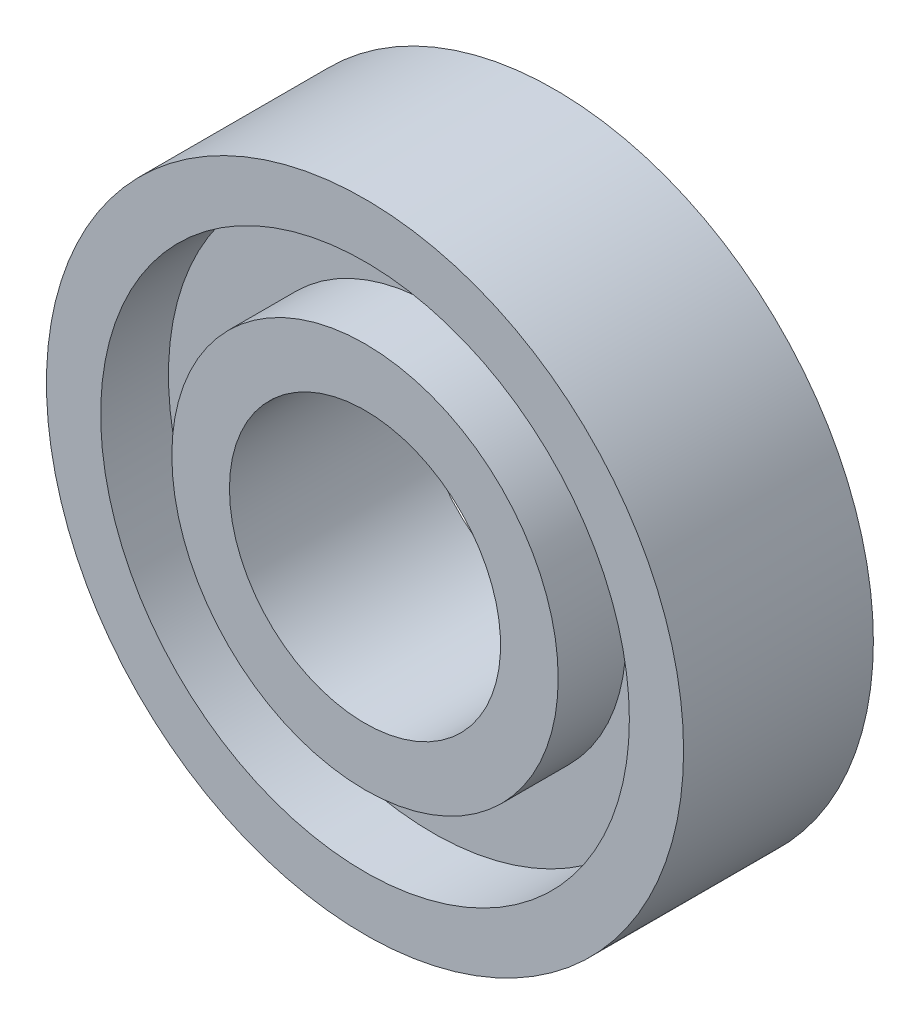
from build123d import *

# Parameters (mm, degrees)
SKETCH1_R      = 23.5
EXTRUDE1_DEPTH = 14
SKETCH2_R      = 19.5
SKETCH2_R_2    = 14.25
EXTRUDE2_DEPTH = 5
SKETCH3_R      = 19.5
SKETCH3_R_2    = 14.25
EXTRUDE3_DEPTH = 5
SKETCH4_R      = 10
EXTRUDE4_DEPTH = 15


with BuildPart() as part:
    # Sketch1 → Extrude1 (new body)
    with BuildSketch(Plane.XY):
        Circle(SKETCH1_R)
    extrude(amount=EXTRUDE1_DEPTH)

    # Sketch2 → Extrude2 (cut)
    with BuildSketch(Plane.XY.offset(14)):
        Circle(SKETCH2_R)
        Circle(SKETCH2_R_2, mode=Mode.SUBTRACT)
    extrude(amount=-EXTRUDE2_DEPTH, mode=Mode.SUBTRACT)

    # Sketch3 → Extrude3 (cut)
    with BuildSketch(Plane(origin=(0, 0, 0), x_dir=(-1, 0, 0), z_dir=(0, 0, -1))):
        Circle(SKETCH3_R)
        Circle(SKETCH3_R_2, mode=Mode.SUBTRACT)
    extrude(amount=-EXTRUDE3_DEPTH, mode=Mode.SUBTRACT)

    # Sketch4 → Extrude4 (cut, through all)
    with BuildSketch(Plane(origin=(0, 0, 0), x_dir=(-1, 0, 0), z_dir=(0, 0, -1))):
        Circle(SKETCH4_R)
    extrude(amount=-EXTRUDE4_DEPTH, mode=Mode.SUBTRACT)


solid = part.part
